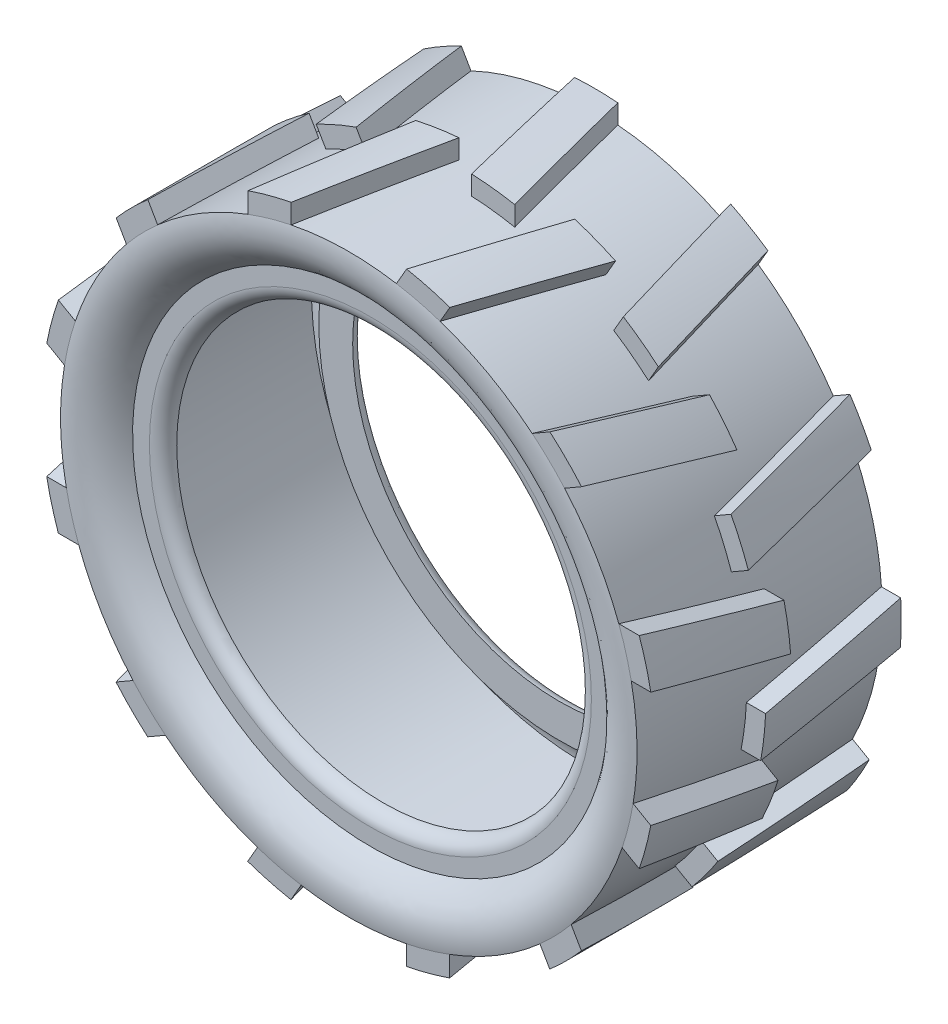
from build123d import *

# Parameters (mm, degrees)
EXTRUDE_1_REACH          = 143.027
PATTERN_CIRCULAR_1_COUNT = 12
SKETCH_3_R               = 81.642849203
SKETCH_3_R_2             = 64
CUT_EXTRUDE_1_DEPTH      = 106.398238127
CUT_EXTRUDE_1_DEPTH_BACK = 106.398238127


with BuildPart() as part:
    # Эскиз1 → Повернуть1 (revolve)
    with BuildSketch(Plane(origin=(0, 0, 0), x_dir=(0, 0, -1), z_dir=(1, 0, 0)), mode=Mode.PRIVATE) as revolve_1_sk:
        with BuildLine():
            Line((0, 60), (25.5, 60))
            add(Edge.make_bspline(
                [(25.5, 60), (26.87392414, 53.731531383), (21, 49.5)],
                knots=[0, 0, 0, 1, 1, 1], degree=2))
            Line((21, 49.5), (21, 46))
            ThreePointArc((21, 46), (20.233438311, 43.981012926), (18.309499833, 43))
            Line((18.309499833, 43), (18.309499833, 46))
            Line((18.309499833, 46), (18.309499833, 50.052245881))
            Line((18.309499833, 50.052245881), (19.830971021, 51.122766541))
            add(Edge.make_bspline(
                [(23.727210277, 57.000001924), (23.698095797, 56.695947897), (23.549438985, 55.802338787), (23.114489215, 54.672185135), (22.402847503, 53.561439088), (21.715390804, 52.73438959), (20.880135901, 51.926289864), (20.180202764, 51.374350498), (19.830971021, 51.122766541)],
                knots=[0.266180621, 0.266180621, 0.266180621, 0.266180621, 0.367957178, 0.578638119, 0.683978589, 0.789319059, 0.89465953, 1, 1, 1, 1], degree=3))
            Line((23.727210277, 57.000001924), (0, 57.000001924))
            Line((0, 57.000001924), (-23.727247353, 57))
            add(Edge.make_bspline(
                [(-23.727247353, 57), (-23.698095969, 56.695948927), (-23.549439173, 55.802339274), (-23.114489215, 54.672185135), (-22.402847503, 53.561439088), (-21.715390804, 52.73438959), (-20.880135901, 51.926289864), (-20.180202764, 51.374350498), (-19.830971021, 51.122766541)],
                knots=[0.266180441, 0.266180441, 0.266180441, 0.266180441, 0.367957178, 0.578638119, 0.683978589, 0.789319059, 0.89465953, 1, 1, 1, 1], degree=3))
            Line((-19.830971021, 51.122766541), (-18.309499833, 50.052245881))
            Line((-18.309499833, 50.052245881), (-18.309499833, 46))
            Line((-18.309499833, 46), (-18.309499833, 43))
            ThreePointArc((-18.309499833, 43), (-20.233438311, 43.981012926), (-21, 46))
            Line((-21, 46), (-21, 49.5))
            add(Edge.make_bspline(
                [(-25.5, 60), (-26.87392414, 53.731531383), (-21, 49.5)],
                knots=[0, 0, 0, 1, 1, 1], degree=2))
            Line((-25.5, 60), (0, 60))
        make_face()
    revolve(revolve_1_sk.sketch.rotate(Axis((0, 0, 131.047552284), (0, 0, -1)), 90), axis=Axis((0, 0, 131.047552284), (0, 0, -1)))

    # Эскиз2 → Бобышка-Вытянуть1 (add, up to next)
    with BuildSketch(Plane(origin=(0, 65, 0), x_dir=(1, 0, 0), z_dir=(0, 1, 0)), mode=Mode.PRIVATE) as extrude_1_sk1:
        Polygon((-5.259945351, 2.685820354), (-12, -25.5), (-21, -25.5), (-14.259945351, 2.685820354), align=None)
    extrude_1_tool1 = extrude(extrude_1_sk1.sketch, amount=-EXTRUDE_1_REACH, mode=Mode.PRIVATE) - part.part
    # Эскиз2 → Бобышка-Вытянуть1 (add, up to next)
    with BuildSketch(Plane(origin=(0, 65, 0), x_dir=(1, 0, 0), z_dir=(0, 1, 0)), mode=Mode.PRIVATE) as extrude_1_sk2:
        Polygon((5, 25.5), (-4, 25.5), (2.740054649, -2.685820354), (11.740054649, -2.685820354), align=None)
    extrude_1_tool2 = extrude(extrude_1_sk2.sketch, amount=-EXTRUDE_1_REACH, mode=Mode.PRIVATE) - part.part
    extrude_1_1 = extrude_1_tool1.solids().sort_by_distance((-13.129973, 65, 11.40709))[0]
    add(extrude_1_1)
    extrude_1_2 = extrude_1_tool2.solids().sort_by_distance((3.870027, 65, -11.40709))[0]
    add(extrude_1_2)
    extrude_1 = extrude_1_1 + extrude_1_2  # Бобышка-Вытянуть1 as one shape, for the pattern or mirror that repeats it

    # Круговой массив1: Бобышка-Вытянуть1 ×12 about axis
    pattern_circular_1_axis = Axis((0, 0, 0), (0, 0, 1))
    for i in range(1, PATTERN_CIRCULAR_1_COUNT):
        add(extrude_1.rotate(pattern_circular_1_axis, i * 360 / PATTERN_CIRCULAR_1_COUNT))

    # Эскиз3 → Вырез-Вытянуть1 (cut, two sides)
    with BuildSketch(Plane.XY.offset(21)) as cut_extrude_1_sk:
        Circle(SKETCH_3_R)
        Circle(SKETCH_3_R_2, mode=Mode.SUBTRACT)
    extrude(amount=CUT_EXTRUDE_1_DEPTH, mode=Mode.SUBTRACT)
    extrude(cut_extrude_1_sk.sketch, amount=-CUT_EXTRUDE_1_DEPTH_BACK, mode=Mode.SUBTRACT)


solid = part.part
